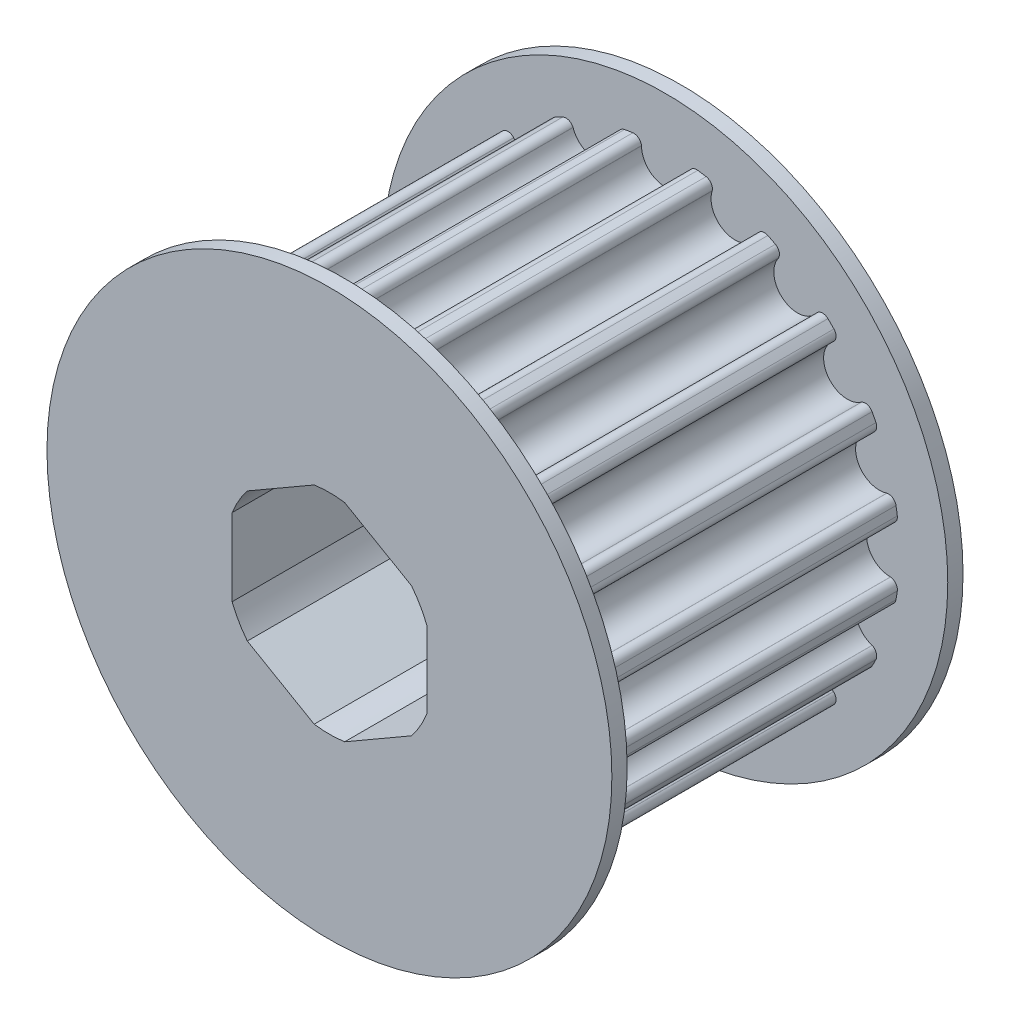
from build123d import *

# Parameters (mm, degrees)
SKETCH2_R                = 15.343994309
BOSS_EXTRUDE1_DEPTH      = 21
CUT_EXTRUDE1_DEPTH       = 22
FILLET1_R                = 0.5
CIRPATTERN1_COUNT        = 20
FILLET1_OF_CIRPATTERN1_R = 0.5
CUT_EXTRUDE2_DEPTH       = 22
SKETCH7_R                = 18.5
BOSS_EXTRUDE2_DEPTH      = 1


with BuildPart() as part:
    # Sketch2 → Boss-Extrude1 (new body)
    with BuildSketch(Plane.XY):
        Circle(SKETCH2_R)
    extrude(amount=BOSS_EXTRUDE1_DEPTH)

    # Sketch3 → Cut-Extrude1 (cut, through all)
    with BuildSketch(Plane(origin=(0, 0, 0), x_dir=(-1, 0, 0), z_dir=(0, 0, -1))):
        with BuildLine():
            Line((-1.614471729, 15.258821789), (-1.56, 14.743994309))
            ThreePointArc((-1.56, 14.743994309), (0, 13.183994309), (1.56, 14.743994309))
            Line((1.56, 14.743994309), (1.614471729, 15.258821789))
            ThreePointArc((1.614471729, 15.258821789), (0, 15.343994309), (-1.614471729, 15.258821789))
        make_face()
    cut_extrude1 = extrude(amount=-CUT_EXTRUDE1_DEPTH, mode=Mode.SUBTRACT)

    # Fillet1
    fillet1_edges = [part.edges().sort_by_distance(p)[0] for p in [
        (1.614471729, 15.258821789, 10.5),
        (-1.614471729, 15.258821789, 10.5),
    ]]
    fillet(fillet1_edges, radius=FILLET1_R)

    # CirPattern1: Cut-Extrude1 ×20 about axis
    cirpattern1_axis = Axis((0, 0, 0), (0, 0, 1))
    for i in range(1, CIRPATTERN1_COUNT):
        add(cut_extrude1.rotate(cirpattern1_axis, i * 360 / CIRPATTERN1_COUNT), mode=Mode.SUBTRACT)

    # Fillet1 of CirPattern1
    fillet1_of_cirpattern1_edges = [part.edges().sort_by_distance(p)[0] for p in [
        (-3.179781388, 15.010901095, 10.5),
        (-6.250689106, 14.013102692, 10.5),
        (-7.662775349, 13.293608814, 10.5),
        (-10.275045481, 11.395683469, 10.5),
        (-11.395683469, 10.275045481, 10.5),
        (-13.293608814, 7.662775349, 10.5),
        (-14.013102692, 6.250689106, 10.5),
        (-15.010901095, 3.179781388, 10.5),
        (-15.258821789, 1.614471729, 10.5),
        (-15.258821789, -1.614471729, 10.5),
        (-15.010901095, -3.179781388, 10.5),
        (-14.013102692, -6.250689106, 10.5),
        (-13.293608814, -7.662775349, 10.5),
        (-11.395683469, -10.275045481, 10.5),
        (-10.275045481, -11.395683469, 10.5),
        (-7.662775349, -13.293608814, 10.5),
        (-6.250689106, -14.013102692, 10.5),
        (-3.179781388, -15.010901095, 10.5),
        (-1.614471729, -15.258821789, 10.5),
        (1.614471729, -15.258821789, 10.5),
        (3.179781388, -15.010901095, 10.5),
        (6.250689106, -14.013102692, 10.5),
        (7.662775349, -13.293608814, 10.5),
        (10.275045481, -11.395683469, 10.5),
        (11.395683469, -10.275045481, 10.5),
        (13.293608814, -7.662775349, 10.5),
        (14.013102692, -6.250689106, 10.5),
        (15.010901095, -3.179781388, 10.5),
        (15.258821789, -1.614471729, 10.5),
        (15.258821789, 1.614471729, 10.5),
        (15.010901095, 3.179781388, 10.5),
        (14.013102692, 6.250689106, 10.5),
        (13.293608814, 7.662775349, 10.5),
        (11.395683469, 10.275045481, 10.5),
        (10.275045481, 11.395683469, 10.5),
        (7.662775349, 13.293608814, 10.5),
        (6.250689106, 14.013102692, 10.5),
        (3.179781388, 15.010901095, 10.5),
    ]]
    fillet(fillet1_of_cirpattern1_edges, radius=FILLET1_OF_CIRPATTERN1_R)

    # Sketch5 → Cut-Extrude2 (cut, through all)
    with BuildSketch(Plane(origin=(0, 0, 0), x_dir=(-1, 0, 0), z_dir=(0, 0, -1))):
        with BuildLine():
            Line((-6.3754, 2.527140447), (-6.3754, -2.527140447))
            ThreePointArc((-6.3754, -2.527140447), (-5.939202219, -3.429), (-5.376267826, -4.257688136))
            Line((-5.376267826, -4.257688136), (-0.999132174, -6.784828583))
            ThreePointArc((-0.999132174, -6.784828583), (0, -6.858), (0.999132174, -6.784828583))
            Line((0.999132174, -6.784828583), (5.376267826, -4.257688136))
            ThreePointArc((5.376267826, -4.257688136), (5.939202219, -3.429), (6.3754, -2.527140447))
            Line((6.3754, -2.527140447), (6.3754, 2.527140447))
            ThreePointArc((6.3754, 2.527140447), (5.939202219, 3.429), (5.376267826, 4.257688136))
            Line((5.376267826, 4.257688136), (0.999132174, 6.784828583))
            ThreePointArc((0.999132174, 6.784828583), (0, 6.858), (-0.999132174, 6.784828583))
            Line((-0.999132174, 6.784828583), (-5.376267826, 4.257688136))
            ThreePointArc((-5.376267826, 4.257688136), (-5.939202219, 3.429), (-6.3754, 2.527140447))
        make_face()
    extrude(amount=-CUT_EXTRUDE2_DEPTH, mode=Mode.SUBTRACT)

    # Sketch7 → Boss-Extrude2 (add)
    with BuildSketch(Plane.XY.offset(21)):
        Circle(SKETCH7_R)
        with BuildLine():
            Line((6.3754, -2.527140447), (6.3754, 2.527140447))
            ThreePointArc((6.3754, 2.527140447), (5.939202219, 3.429), (5.376267826, 4.257688136))
            Line((5.376267826, 4.257688136), (0.999132174, 6.784828583))
            ThreePointArc((0.999132174, 6.784828583), (0, 6.858), (-0.999132174, 6.784828583))
            Line((-0.999132174, 6.784828583), (-5.376267826, 4.257688136))
            ThreePointArc((-5.376267826, 4.257688136), (-5.939202219, 3.429), (-6.3754, 2.527140447))
            Line((-6.3754, 2.527140447), (-6.3754, -2.527140447))
            ThreePointArc((-6.3754, -2.527140447), (-5.939202219, -3.429), (-5.376267826, -4.257688136))
            Line((-5.376267826, -4.257688136), (-0.999132174, -6.784828583))
            ThreePointArc((-0.999132174, -6.784828583), (0, -6.858), (0.999132174, -6.784828583))
            Line((0.999132174, -6.784828583), (5.376267826, -4.257688136))
            ThreePointArc((5.376267826, -4.257688136), (5.939202219, -3.429), (6.3754, -2.527140447))
        make_face(mode=Mode.SUBTRACT)
    boss_extrude2 = extrude(amount=BOSS_EXTRUDE2_DEPTH)

    # Mirror1: Boss-Extrude2 across plane
    add(boss_extrude2.mirror(Plane.XY.offset(10.5)))


solid = part.part
